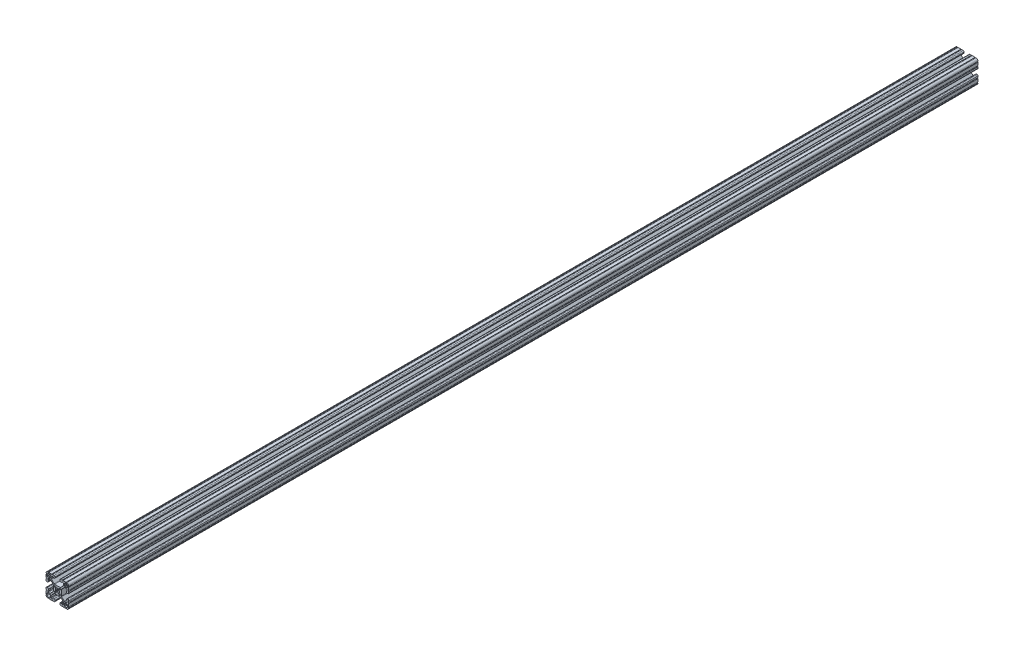
from build123d import *

# Parameters (mm, degrees)
EXTRUDE1_DEPTH = 1524


with BuildPart() as part:
    # Sketch1 → Extrude1 (new body)
    with BuildSketch(Plane.XY):
        with BuildLine():
            Line((6.349777007, -14.984831919), (5.653061318, -14.984831848))
            ThreePointArc((5.653061318, -14.984831848), (4.539002167, -15.446080098), (4.077754017, -16.560139291))
            Line((4.077754017, -16.560139291), (4.077753935, -17.474692556))
            ThreePointArc((4.077753935, -17.474692556), (4.539002158, -18.588751741), (5.653061362, -19.049999918))
            Line((5.653061362, -19.049999918), (7.975599859, -19.05))
            ThreePointArc((7.975599859, -19.05), (8.737599929, -18.288), (9.4996, -19.05))
            Line((9.4996, -19.05), (14.298091988, -19.05))
            ThreePointArc((14.298091988, -19.05), (15.05987163, -18.288000032), (15.822092002, -19.049559142))
            ThreePointArc((15.822092002, -19.049559142), (18.110316678, -18.129769245), (19.049898398, -15.849599993))
            ThreePointArc((19.049898398, -15.849599993), (18.288000002, -15.087549199), (19.05, -14.3256))
            Line((19.05, -14.3256), (19.05, -9.499600141))
            ThreePointArc((19.05, -9.499600141), (18.288, -8.737600071), (19.05, -7.9756))
            Line((19.05, -7.9756), (19.05, -5.653061359))
            ThreePointArc((19.05, -5.653061359), (18.588751763, -4.53900218), (17.474692553, -4.077754017))
            Line((17.474692553, -4.077754017), (16.560139293, -4.077753935))
            ThreePointArc((16.560139293, -4.077753935), (15.446080122, -4.539002143), (14.98483193, -5.653061321))
            Line((14.98483193, -5.653061321), (14.984831848, -6.349776986))
            ThreePointArc((14.984831848, -6.349776986), (15.096428348, -6.619420887), (15.366075744, -6.731008942))
            Line((15.366075744, -6.731008942), (15.696937609, -6.730998691))
            ThreePointArc((15.696937609, -6.730998691), (15.966583472, -6.842585282), (16.078181438, -7.112226438))
            Line((16.078181438, -7.112226438), (16.078207121, -9.396837814))
            ThreePointArc((16.078207121, -9.396837814), (15.817838504, -10.026619018), (15.188068118, -10.287013801))
            Line((15.188068118, -10.287013801), (12.352560476, -10.287103022))
            ThreePointArc((12.352560476, -10.287103022), (11.865894357, -10.190173629), (11.453520834, -9.914153164))
            Line((11.453520834, -9.914153164), (7.114725376, -5.565926641))
            ThreePointArc((7.114725376, -5.565926641), (6.840134749, -5.154247475), (6.7437254, -4.668876499))
            Line((6.7437254, -4.668876499), (6.7437254, 4.641368628))
            ThreePointArc((6.7437254, 4.641368628), (6.840134749, 5.126739605), (7.114725376, 5.53841877))
            Line((7.114725376, 5.53841877), (11.480968187, 9.914152308))
            ThreePointArc((11.480968187, 9.914152308), (11.89334171, 10.190172773), (12.380007829, 10.287102166))
            Line((12.380007829, 10.287102166), (15.188068116, 10.287014567))
            ThreePointArc((15.188068116, 10.287014567), (15.817838279, 10.026619243), (16.078206356, 9.396837815))
            Line((16.078206356, 9.396837815), (16.078181509, 7.1122265))
            ThreePointArc((16.078181509, 7.1122265), (15.966583514, 6.842585324), (15.696937607, 6.730998762))
            Line((15.696937607, 6.730998762), (15.366075744, 6.731009012))
            ThreePointArc((15.366075744, 6.731009012), (15.096428376, 6.619420915), (14.984831919, 6.349777007))
            Line((14.984831919, 6.349777007), (14.984831848, 5.653061318))
            ThreePointArc((14.984831848, 5.653061318), (15.446080098, 4.539002167), (16.560139291, 4.077754017))
            Line((16.560139291, 4.077754017), (17.474692556, 4.077753935))
            ThreePointArc((17.474692556, 4.077753935), (18.588751741, 4.539002158), (19.049999918, 5.653061362))
            Line((19.049999918, 5.653061362), (19.05, 7.975599859))
            ThreePointArc((19.05, 7.975599859), (18.288, 8.737599929), (19.05, 9.4996))
            Line((19.05, 9.4996), (19.05, 14.298091988))
            ThreePointArc((19.05, 14.298091988), (18.288000032, 15.05987163), (19.049559142, 15.822092002))
            ThreePointArc((19.049559142, 15.822092002), (18.129769245, 18.110316678), (15.849599993, 19.049898398))
            ThreePointArc((15.849599993, 19.049898398), (15.087549199, 18.288000002), (14.3256, 19.05))
            Line((14.3256, 19.05), (9.499600141, 19.05))
            ThreePointArc((9.499600141, 19.05), (8.737600071, 18.288), (7.9756, 19.05))
            Line((7.9756, 19.05), (5.653061359, 19.05))
            ThreePointArc((5.653061359, 19.05), (4.53900218, 18.588751763), (4.077754017, 17.474692553))
            Line((4.077754017, 17.474692553), (4.077753935, 16.560139293))
            ThreePointArc((4.077753935, 16.560139293), (4.539002143, 15.446080122), (5.653061321, 14.98483193))
            Line((5.653061321, 14.98483193), (6.349776986, 14.984831848))
            ThreePointArc((6.349776986, 14.984831848), (6.619420887, 15.096428348), (6.731008942, 15.366075744))
            Line((6.731008942, 15.366075744), (6.730998691, 15.696937609))
            ThreePointArc((6.730998691, 15.696937609), (6.842585282, 15.966583472), (7.112226438, 16.078181438))
            Line((7.112226438, 16.078181438), (9.396837814, 16.078207121))
            ThreePointArc((9.396837814, 16.078207121), (10.026619018, 15.817838504), (10.287013801, 15.188068118))
            Line((10.287013801, 15.188068118), (10.287103022, 12.352560476))
            ThreePointArc((10.287103022, 12.352560476), (10.190173629, 11.865894357), (9.914153164, 11.453520834))
            Line((9.914153164, 11.453520834), (5.565926641, 7.114725376))
            ThreePointArc((5.565926641, 7.114725376), (5.154247475, 6.840134749), (4.668876499, 6.7437254))
            Line((4.668876499, 6.7437254), (-4.641368628, 6.7437254))
            ThreePointArc((-4.641368628, 6.7437254), (-5.126739605, 6.840134749), (-5.53841877, 7.114725376))
            Line((-5.53841877, 7.114725376), (-9.914152308, 11.480968187))
            ThreePointArc((-9.914152308, 11.480968187), (-10.190172773, 11.89334171), (-10.287102166, 12.380007829))
            Line((-10.287102166, 12.380007829), (-10.287014567, 15.188068116))
            ThreePointArc((-10.287014567, 15.188068116), (-10.026619243, 15.817838279), (-9.396837815, 16.078206356))
            Line((-9.396837815, 16.078206356), (-7.1122265, 16.078181509))
            ThreePointArc((-7.1122265, 16.078181509), (-6.842585324, 15.966583514), (-6.730998762, 15.696937607))
            Line((-6.730998762, 15.696937607), (-6.731008942, 15.366075744))
            ThreePointArc((-6.731008942, 15.366075744), (-6.619420905, 15.096428366), (-6.349777007, 14.984831919))
            Line((-6.349777007, 14.984831919), (-5.653061318, 14.984831848))
            ThreePointArc((-5.653061318, 14.984831848), (-4.539002167, 15.446080098), (-4.077754017, 16.560139291))
            Line((-4.077754017, 16.560139291), (-4.077753935, 17.474692556))
            ThreePointArc((-4.077753935, 17.474692556), (-4.539002158, 18.588751741), (-5.653061362, 19.049999918))
            Line((-5.653061362, 19.049999918), (-7.975599859, 19.05))
            ThreePointArc((-7.975599859, 19.05), (-8.737599929, 18.288), (-9.4996, 19.05))
            Line((-9.4996, 19.05), (-14.298091988, 19.05))
            ThreePointArc((-14.298091988, 19.05), (-15.05987163, 18.288000032), (-15.822092002, 19.049559142))
            ThreePointArc((-15.822092002, 19.049559142), (-18.110316678, 18.129769245), (-19.049898398, 15.849599993))
            ThreePointArc((-19.049898398, 15.849599993), (-18.288000002, 15.087549199), (-19.05, 14.3256))
            Line((-19.05, 14.3256), (-19.05, 9.499600141))
            ThreePointArc((-19.05, 9.499600141), (-18.288, 8.737600071), (-19.05, 7.9756))
            Line((-19.05, 7.9756), (-19.05, 5.653061359))
            ThreePointArc((-19.05, 5.653061359), (-18.588751763, 4.53900218), (-17.474692553, 4.077754017))
            Line((-17.474692553, 4.077754017), (-16.560139293, 4.077753935))
            ThreePointArc((-16.560139293, 4.077753935), (-15.446080122, 4.539002143), (-14.98483193, 5.653061321))
            Line((-14.98483193, 5.653061321), (-14.984831848, 6.349776986))
            ThreePointArc((-14.984831848, 6.349776986), (-15.096428348, 6.619420887), (-15.366075744, 6.731008942))
            Line((-15.366075744, 6.731008942), (-15.696937609, 6.730998691))
            ThreePointArc((-15.696937609, 6.730998691), (-15.966583472, 6.842585283), (-16.078181438, 7.112226438))
            Line((-16.078181438, 7.112226438), (-16.078207121, 9.396837814))
            ThreePointArc((-16.078207121, 9.396837814), (-15.817838504, 10.026619018), (-15.188068118, 10.287013802))
            Line((-15.188068118, 10.287013802), (-12.352560476, 10.287103022))
            ThreePointArc((-12.352560476, 10.287103022), (-11.865894357, 10.190173629), (-11.453520834, 9.914153164))
            Line((-11.453520834, 9.914153164), (-7.114725376, 5.565926641))
            ThreePointArc((-7.114725376, 5.565926641), (-6.840134749, 5.154247475), (-6.7437254, 4.668876499))
            Line((-6.7437254, 4.668876499), (-6.7437254, -4.641368628))
            ThreePointArc((-6.7437254, -4.641368628), (-6.840134749, -5.126739605), (-7.114725376, -5.53841877))
            Line((-7.114725376, -5.53841877), (-11.480968187, -9.914152308))
            ThreePointArc((-11.480968187, -9.914152308), (-11.89334171, -10.190172773), (-12.380007829, -10.287102166))
            Line((-12.380007829, -10.287102166), (-15.188068116, -10.287014567))
            ThreePointArc((-15.188068116, -10.287014567), (-15.817838279, -10.026619243), (-16.078206356, -9.396837815))
            Line((-16.078206356, -9.396837815), (-16.078181509, -7.1122265))
            ThreePointArc((-16.078181509, -7.1122265), (-15.966583514, -6.842585324), (-15.696937607, -6.730998762))
            Line((-15.696937607, -6.730998762), (-15.366075744, -6.731009012))
            ThreePointArc((-15.366075744, -6.731009012), (-15.096428376, -6.619420915), (-14.984831919, -6.349777007))
            Line((-14.984831919, -6.349777007), (-14.984831848, -5.653061318))
            ThreePointArc((-14.984831848, -5.653061318), (-15.446080098, -4.539002167), (-16.560139291, -4.077754017))
            Line((-16.560139291, -4.077754017), (-17.474692556, -4.077753935))
            ThreePointArc((-17.474692556, -4.077753935), (-18.588751741, -4.539002158), (-19.049999918, -5.653061362))
            Line((-19.049999918, -5.653061362), (-19.05, -7.975599859))
            ThreePointArc((-19.05, -7.975599859), (-18.288, -8.737599929), (-19.05, -9.4996))
            Line((-19.05, -9.4996), (-19.05, -14.298091988))
            ThreePointArc((-19.05, -14.298091988), (-18.288000032, -15.05987163), (-19.049559142, -15.822092002))
            ThreePointArc((-19.049559142, -15.822092002), (-18.129769245, -18.110316678), (-15.849599993, -19.049898398))
            ThreePointArc((-15.849599993, -19.049898398), (-15.087549199, -18.288000002), (-14.3256, -19.05))
            Line((-14.3256, -19.05), (-9.499600141, -19.05))
            ThreePointArc((-9.499600141, -19.05), (-8.737600071, -18.288), (-7.9756, -19.05))
            Line((-7.9756, -19.05), (-5.653061359, -19.05))
            ThreePointArc((-5.653061359, -19.05), (-4.53900218, -18.588751763), (-4.077754017, -17.474692553))
            Line((-4.077754017, -17.474692553), (-4.077753935, -16.560139293))
            ThreePointArc((-4.077753935, -16.560139293), (-4.539002143, -15.446080122), (-5.653061321, -14.98483193))
            Line((-5.653061321, -14.98483193), (-6.349776986, -14.984831848))
            ThreePointArc((-6.349776986, -14.984831848), (-6.619420887, -15.096428348), (-6.731008942, -15.366075744))
            Line((-6.731008942, -15.366075744), (-6.730998691, -15.696937609))
            ThreePointArc((-6.730998691, -15.696937609), (-6.842585282, -15.966583472), (-7.112226438, -16.078181438))
            Line((-7.112226438, -16.078181438), (-9.396837814, -16.078207121))
            ThreePointArc((-9.396837814, -16.078207121), (-10.026619018, -15.817838504), (-10.287013801, -15.188068118))
            Line((-10.287013801, -15.188068118), (-10.287103022, -12.352560476))
            ThreePointArc((-10.287103022, -12.352560476), (-10.190173629, -11.865894357), (-9.914153164, -11.453520834))
            Line((-9.914153164, -11.453520834), (-5.565926641, -7.114725376))
            ThreePointArc((-5.565926641, -7.114725376), (-5.154247475, -6.840134749), (-4.668876499, -6.7437254))
            Line((-4.668876499, -6.7437254), (4.641368628, -6.7437254))
            ThreePointArc((4.641368628, -6.7437254), (5.126739605, -6.840134749), (5.53841877, -7.114725376))
            Line((5.53841877, -7.114725376), (9.914152308, -11.480968187))
            ThreePointArc((9.914152308, -11.480968187), (10.190172773, -11.89334171), (10.287102166, -12.380007829))
            Line((10.287102166, -12.380007829), (10.287014567, -15.188068116))
            ThreePointArc((10.287014567, -15.188068116), (10.026619243, -15.817838279), (9.396837815, -16.078206356))
            Line((9.396837815, -16.078206356), (7.1122265, -16.078181509))
            ThreePointArc((7.1122265, -16.078181509), (6.842585324, -15.966583514), (6.730998762, -15.696937607))
            Line((6.730998762, -15.696937607), (6.731008942, -15.366075744))
            ThreePointArc((6.731008942, -15.366075744), (6.619420905, -15.096428366), (6.349777007, -14.984831919))
        make_face()
        with BuildLine():
            Line((1.582347442, 3.198793543), (3.292097227, 4.908543328))
            ThreePointArc((3.292097227, 4.908543328), (3.580509584, 5.101254304), (3.920715155, 5.1689254))
            Line((3.920715155, 5.1689254), (4.9149254, 5.1689254))
            ThreePointArc((4.9149254, 5.1689254), (5.094530522, 5.094530522), (5.1689254, 4.9149254))
            Line((5.1689254, 4.9149254), (5.1689254, 3.920715155))
            ThreePointArc((5.1689254, 3.920715155), (5.101254304, 3.580509584), (4.908543328, 3.292097227))
            Line((4.908543328, 3.292097227), (3.198793543, 1.582347442))
            ThreePointArc((3.198793543, 1.582347442), (3.095711236, 1.393016011), (3.111879183, 1.178048687))
            ThreePointArc((3.111879183, 1.178048687), (3.3274, 0), (3.111879183, -1.178048687))
            ThreePointArc((3.111879183, -1.178048687), (3.095711236, -1.393016011), (3.198793543, -1.582347442))
            Line((3.198793543, -1.582347442), (4.908543328, -3.292097227))
            ThreePointArc((4.908543328, -3.292097227), (5.101254304, -3.580509584), (5.1689254, -3.920715155))
            Line((5.1689254, -3.920715155), (5.1689254, -4.9149254))
            ThreePointArc((5.1689254, -4.9149254), (5.094530522, -5.094530522), (4.9149254, -5.1689254))
            Line((4.9149254, -5.1689254), (3.920715155, -5.1689254))
            ThreePointArc((3.920715155, -5.1689254), (3.580509584, -5.101254304), (3.292097227, -4.908543328))
            Line((3.292097227, -4.908543328), (1.582347442, -3.198793543))
            ThreePointArc((1.582347442, -3.198793543), (1.393016011, -3.095711236), (1.178048687, -3.111879183))
            ThreePointArc((1.178048687, -3.111879183), (0, -3.3274), (-1.178048687, -3.111879183))
            ThreePointArc((-1.178048687, -3.111879183), (-1.393016011, -3.095711236), (-1.582347442, -3.198793543))
            Line((-1.582347442, -3.198793543), (-3.292097227, -4.908543328))
            ThreePointArc((-3.292097227, -4.908543328), (-3.580509584, -5.101254304), (-3.920715155, -5.1689254))
            Line((-3.920715155, -5.1689254), (-4.9149254, -5.1689254))
            ThreePointArc((-4.9149254, -5.1689254), (-5.094530522, -5.094530522), (-5.1689254, -4.9149254))
            Line((-5.1689254, -4.9149254), (-5.1689254, -3.920715155))
            ThreePointArc((-5.1689254, -3.920715155), (-5.101254304, -3.580509584), (-4.908543328, -3.292097227))
            Line((-4.908543328, -3.292097227), (-3.198793543, -1.582347442))
            ThreePointArc((-3.198793543, -1.582347442), (-3.095711236, -1.393016011), (-3.111879183, -1.178048687))
            ThreePointArc((-3.111879183, -1.178048687), (-3.3274, 0), (-3.111879183, 1.178048687))
            ThreePointArc((-3.111879183, 1.178048687), (-3.095711236, 1.393016011), (-3.198793543, 1.582347442))
            Line((-3.198793543, 1.582347442), (-4.908543328, 3.292097227))
            ThreePointArc((-4.908543328, 3.292097227), (-5.101254304, 3.580509584), (-5.1689254, 3.920715155))
            Line((-5.1689254, 3.920715155), (-5.1689254, 4.9149254))
            ThreePointArc((-5.1689254, 4.9149254), (-5.094530522, 5.094530522), (-4.9149254, 5.1689254))
            Line((-4.9149254, 5.1689254), (-3.920715155, 5.1689254))
            ThreePointArc((-3.920715155, 5.1689254), (-3.580509584, 5.101254304), (-3.292097227, 4.908543328))
            Line((-3.292097227, 4.908543328), (-1.582347442, 3.198793543))
            ThreePointArc((-1.582347442, 3.198793543), (-1.393016011, 3.095711236), (-1.178048687, 3.111879183))
            ThreePointArc((-1.178048687, 3.111879183), (0, 3.3274), (1.178048687, 3.111879183))
            ThreePointArc((1.178048687, 3.111879183), (1.393016011, 3.095711236), (1.582347442, 3.198793543))
        make_face(mode=Mode.SUBTRACT)
        with BuildLine():
            Line((-11.8669054, 14.019430433), (-11.8669054, 12.24788))
            ThreePointArc((-11.8669054, 12.24788), (-11.978497716, 11.978472316), (-12.2479054, 11.86688))
            Line((-12.2479054, 11.86688), (-14.019455833, 11.86688))
            ThreePointArc((-14.019455833, 11.86688), (-14.020427836, 11.867073341), (-14.021251865, 11.867623929))
            Line((-14.021251865, 11.867623929), (-14.557512425, 12.403872831))
            ThreePointArc((-14.557512425, 12.403872831), (-14.559308484, 12.404616761), (-14.561104527, 12.403872792))
            Line((-14.561104527, 12.403872792), (-15.097341694, 11.867623968))
            ThreePointArc((-15.097341694, 11.867623968), (-15.098165736, 11.867073351), (-15.099137765, 11.86688))
            Line((-15.099137765, 11.86688), (-16.8707054, 11.86688))
            ThreePointArc((-16.8707054, 11.86688), (-17.140113084, 11.978472316), (-17.2517054, 12.24788))
            Line((-17.2517054, 12.24788), (-17.2517054, 14.45768))
            ThreePointArc((-17.2517054, 14.45768), (-16.433361747, 16.433336347), (-14.4577054, 17.25168))
            Line((-14.4577054, 17.25168), (-12.2479054, 17.25168))
            ThreePointArc((-12.2479054, 17.25168), (-11.978497716, 17.140087684), (-11.8669054, 16.87068))
            Line((-11.8669054, 16.87068), (-11.8669054, 15.099112365))
            ThreePointArc((-11.8669054, 15.099112365), (-11.867098751, 15.098140336), (-11.867649368, 15.097316294))
            Line((-11.867649368, 15.097316294), (-12.403898192, 14.561079127))
            ThreePointArc((-12.403898192, 14.561079127), (-12.40464216, 14.559283084), (-12.403898231, 14.557487025))
            Line((-12.403898231, 14.557487025), (-11.867649329, 14.021226465))
            ThreePointArc((-11.867649329, 14.021226465), (-11.867098741, 14.020402437), (-11.8669054, 14.019430433))
        make_face(mode=Mode.SUBTRACT)
        with BuildLine():
            Line((-14.019430433, -11.8669054), (-12.24788, -11.8669054))
            ThreePointArc((-12.24788, -11.8669054), (-11.978472316, -11.978497716), (-11.86688, -12.2479054))
            Line((-11.86688, -12.2479054), (-11.86688, -14.019455833))
            ThreePointArc((-11.86688, -14.019455833), (-11.867073341, -14.020427836), (-11.867623929, -14.021251865))
            Line((-11.867623929, -14.021251865), (-12.403872831, -14.557512425))
            ThreePointArc((-12.403872831, -14.557512425), (-12.404616761, -14.559308484), (-12.403872792, -14.561104527))
            Line((-12.403872792, -14.561104527), (-11.867623968, -15.097341694))
            ThreePointArc((-11.867623968, -15.097341694), (-11.867073351, -15.098165736), (-11.86688, -15.099137765))
            Line((-11.86688, -15.099137765), (-11.86688, -16.8707054))
            ThreePointArc((-11.86688, -16.8707054), (-11.978472316, -17.140113083), (-12.24788, -17.2517054))
            Line((-12.24788, -17.2517054), (-14.45768, -17.2517054))
            ThreePointArc((-14.45768, -17.2517054), (-16.433336347, -16.433361746), (-17.25168, -14.4577054))
            Line((-17.25168, -14.4577054), (-17.25168, -12.2479054))
            ThreePointArc((-17.25168, -12.2479054), (-17.140087684, -11.978497716), (-16.87068, -11.8669054))
            Line((-16.87068, -11.8669054), (-15.099112365, -11.8669054))
            ThreePointArc((-15.099112365, -11.8669054), (-15.098140336, -11.867098751), (-15.097316294, -11.867649368))
            Line((-15.097316294, -11.867649368), (-14.561079127, -12.403898192))
            ThreePointArc((-14.561079127, -12.403898192), (-14.559283084, -12.40464216), (-14.557487025, -12.403898231))
            Line((-14.557487025, -12.403898231), (-14.021226465, -11.867649329))
            ThreePointArc((-14.021226465, -11.867649329), (-14.020402437, -11.867098741), (-14.019430433, -11.8669054))
        make_face(mode=Mode.SUBTRACT)
        with BuildLine():
            Line((11.8669054, -14.019430433), (11.8669054, -12.24788))
            ThreePointArc((11.8669054, -12.24788), (11.978497716, -11.978472316), (12.2479054, -11.86688))
            Line((12.2479054, -11.86688), (14.019455833, -11.86688))
            ThreePointArc((14.019455833, -11.86688), (14.020427836, -11.867073341), (14.021251865, -11.867623929))
            Line((14.021251865, -11.867623929), (14.557512425, -12.403872831))
            ThreePointArc((14.557512425, -12.403872831), (14.559308484, -12.404616761), (14.561104527, -12.403872792))
            Line((14.561104527, -12.403872792), (15.097341694, -11.867623968))
            ThreePointArc((15.097341694, -11.867623968), (15.098165736, -11.867073351), (15.099137765, -11.86688))
            Line((15.099137765, -11.86688), (16.8707054, -11.86688))
            ThreePointArc((16.8707054, -11.86688), (17.140113084, -11.978472316), (17.2517054, -12.24788))
            Line((17.2517054, -12.24788), (17.2517054, -14.45768))
            ThreePointArc((17.2517054, -14.45768), (16.433361747, -16.433336347), (14.4577054, -17.25168))
            Line((14.4577054, -17.25168), (12.2479054, -17.25168))
            ThreePointArc((12.2479054, -17.25168), (11.978497716, -17.140087684), (11.8669054, -16.87068))
            Line((11.8669054, -16.87068), (11.8669054, -15.099112365))
            ThreePointArc((11.8669054, -15.099112365), (11.867098751, -15.098140336), (11.867649368, -15.097316294))
            Line((11.867649368, -15.097316294), (12.403898192, -14.561079127))
            ThreePointArc((12.403898192, -14.561079127), (12.40464216, -14.559283084), (12.403898231, -14.557487025))
            Line((12.403898231, -14.557487025), (11.867649329, -14.021226465))
            ThreePointArc((11.867649329, -14.021226465), (11.867098741, -14.020402436), (11.8669054, -14.019430433))
        make_face(mode=Mode.SUBTRACT)
        with BuildLine():
            Line((14.019430433, 11.8669054), (12.24788, 11.8669054))
            ThreePointArc((12.24788, 11.8669054), (11.978472316, 11.978497716), (11.86688, 12.2479054))
            Line((11.86688, 12.2479054), (11.86688, 14.019455833))
            ThreePointArc((11.86688, 14.019455833), (11.867073341, 14.020427836), (11.867623929, 14.021251865))
            Line((11.867623929, 14.021251865), (12.403872831, 14.557512425))
            ThreePointArc((12.403872831, 14.557512425), (12.404616761, 14.559308484), (12.403872792, 14.561104527))
            Line((12.403872792, 14.561104527), (11.867623968, 15.097341694))
            ThreePointArc((11.867623968, 15.097341694), (11.867073351, 15.098165736), (11.86688, 15.099137765))
            Line((11.86688, 15.099137765), (11.86688, 16.8707054))
            ThreePointArc((11.86688, 16.8707054), (11.978472316, 17.140113084), (12.24788, 17.2517054))
            Line((12.24788, 17.2517054), (14.45768, 17.2517054))
            ThreePointArc((14.45768, 17.2517054), (16.433336347, 16.433361747), (17.25168, 14.4577054))
            Line((17.25168, 14.4577054), (17.25168, 12.2479054))
            ThreePointArc((17.25168, 12.2479054), (17.140087684, 11.978497716), (16.87068, 11.8669054))
            Line((16.87068, 11.8669054), (15.099112365, 11.8669054))
            ThreePointArc((15.099112365, 11.8669054), (15.098140336, 11.867098751), (15.097316294, 11.867649368))
            Line((15.097316294, 11.867649368), (14.561079127, 12.403898192))
            ThreePointArc((14.561079127, 12.403898192), (14.559283084, 12.404642161), (14.557487025, 12.403898231))
            Line((14.557487025, 12.403898231), (14.021226465, 11.867649329))
            ThreePointArc((14.021226465, 11.867649329), (14.020402436, 11.867098741), (14.019430433, 11.8669054))
        make_face(mode=Mode.SUBTRACT)
    extrude(amount=-EXTRUDE1_DEPTH)


solid = part.part
